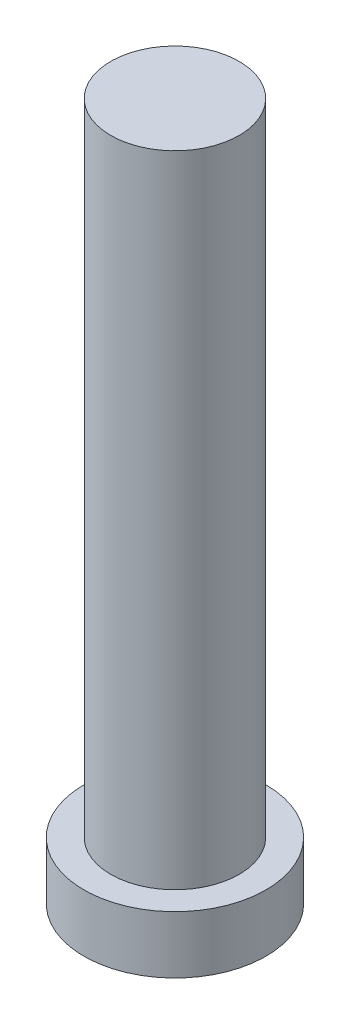
from build123d import *

# Parameters (mm, degrees)
SKETCH1_R           = 3.35
BOSS_EXTRUDE1_DEPTH = 33.4
SKETCH2_R           = 4.75
BOSS_EXTRUDE2_DEPTH = 3


with BuildPart() as part:
    # Sketch1 → Boss-Extrude1 (new body)
    with BuildSketch(Plane(origin=(0, 0, 0), x_dir=(1, 0, 0), z_dir=(0, 1, 0))):
        Circle(SKETCH1_R)
    extrude(amount=BOSS_EXTRUDE1_DEPTH)

    # Sketch2 → Boss-Extrude2 (add)
    with BuildSketch(Plane.XZ):
        Circle(SKETCH2_R)
    extrude(amount=BOSS_EXTRUDE2_DEPTH)


solid = part.part
